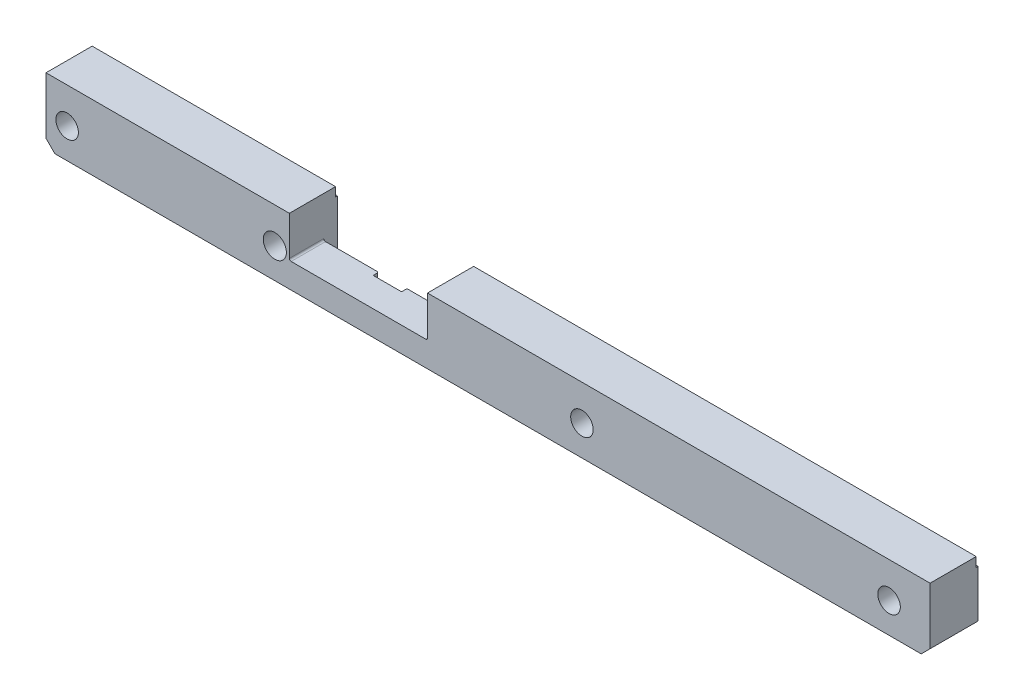
from build123d import *

# Parameters (mm, degrees)
SKETCH1_W               = 498
SKETCH1_H               = 37
BOSS_EXTRUDE1_DEPTH     = 27
SKETCH3_W               = 30
SKETCH3_H               = 27
CUT_EXTRUDE2_DEPTH      = 4
SKETCH4_W               = 77.8
SKETCH4_H               = 23
CUT_EXTRUDE3_DEPTH      = 28
SKETCH5_W               = 77.8
SKETCH5_H               = 7.65
CUT_EXTRUDE4_DEPTH      = 15
SKETCH6_W               = 16
SKETCH6_H               = 14
CUT_EXTRUDE5_DEPTH      = 3.05
CUT_EXTRUDE6_DEPTH      = 1
M3_TAPPED_HOLE1_D       = 2.5
M3_TAPPED_HOLE1_DEPTH   = 6
M3_TAPPED_HOLE1_TIP     = 0.751075774
M4_TAPPED_HOLE1_D       = 3.3
M4_TAPPED_HOLE1_DEPTH   = 8
M4_TAPPED_HOLE1_TIP     = 0.991420021
M3_TAPPED_HOLE2_D       = 2.5
M3_TAPPED_HOLE2_DEPTH   = 6
M3_TAPPED_HOLE2_TIP     = 0.751075774
M3_TAPPED_HOLE3_D       = 2.5
M3_TAPPED_HOLE3_DEPTH   = 6
M3_TAPPED_HOLE3_TIP     = 0.751075774
SKETCH16_W              = 10
SKETCH16_H              = 33
CUT_EXTRUDE7_DEPTH      = 0.4
FILLET1_R               = 1
CHAMFER1_SIZE           = 0.5
FILLET2_R               = 1
CHAMFER2_SIZE           = 5
SKETCH17_R              = 1.5
CUT_EXTRUDE8_DEPTH      = 6
SKETCH19_R              = 6.347203473
SKETCH19_R_2            = 6.528534634
CUT_EXTRUDE9_DEPTH      = 28
M3_5_TAPPED_HOLE1_D     = 2.9
M3_5_TAPPED_HOLE1_DEPTH = 5
M3_5_TAPPED_HOLE1_TIP   = 0.871247898
M4_TAPPED_HOLE3_D       = 3.3
M4_TAPPED_HOLE3_DEPTH   = 7
M4_TAPPED_HOLE3_TIP     = 0.991420021


with BuildPart() as part:
    # Sketch1 → Boss-Extrude1 (new body)
    with BuildSketch(Plane.XY):
        with Locations((97.902272727, 23.094318182)):
            Rectangle(SKETCH1_W, SKETCH1_H)
    extrude(amount=BOSS_EXTRUDE1_DEPTH)

    # Sketch3 → Cut-Extrude2 (cut)
    with BuildSketch(Plane(origin=(0, 0, 0), x_dir=(-1, 0, 0), z_dir=(0, 0, -1))):
        with Locations((-279.902272727, 18.094318182)):
            Rectangle(SKETCH3_W, SKETCH3_H)
    extrude(amount=-CUT_EXTRUDE2_DEPTH, mode=Mode.SUBTRACT)

    # Sketch4 → Cut-Extrude3 (cut, through all)
    with BuildSketch(Plane(origin=(0, 0, 0), x_dir=(-1, 0, 0), z_dir=(0, 0, -1))):
        with Locations((-24.902272727, 30.094318182)):
            Rectangle(SKETCH4_W, SKETCH4_H)
    extrude(amount=-CUT_EXTRUDE3_DEPTH, mode=Mode.SUBTRACT)

    # Sketch5 → Cut-Extrude4 (cut, through all)
    with BuildSketch(Plane(origin=(0, 18.594318182, 0), x_dir=(1, 0, 0), z_dir=(0, 1, 0))):
        with Locations((24.902272727, -3.825)):
            Rectangle(SKETCH5_W, SKETCH5_H)
    extrude(amount=-CUT_EXTRUDE4_DEPTH, mode=Mode.SUBTRACT)

    # Sketch6 → Cut-Extrude5 (cut)
    with BuildSketch(Plane(origin=(0, 0, 7.65), x_dir=(-1, 0, 0), z_dir=(0, 0, -1))):
        with Locations((-24.902272727, 11.594318182)):
            Rectangle(SKETCH6_W, SKETCH6_H)
    extrude(amount=-CUT_EXTRUDE5_DEPTH, mode=Mode.SUBTRACT)

    # Sketch7 → Cut-Extrude6 (cut)
    with BuildSketch(Plane(origin=(0, 0, 0), x_dir=(-1, 0, 0), z_dir=(0, 0, -1))):
        Polygon((151.097727273, 36.25457222), (146.097727273, 37.594318182), (18.242292409, 37.594318182), (13.997727273, 36.456990381), (13.997727273, 37.594318182), (-63.802272727, 37.594318182), (-341.902272727, 37.594318182), (-346.902272727, 36.25457222), (-346.902272727, 41.594318182), (151.097727273, 41.594318182), align=None)
    extrude(amount=-CUT_EXTRUDE6_DEPTH, mode=Mode.SUBTRACT)

    # M3 Tapped Hole1
    with Locations(Plane(origin=(0, 4.594318182, 0), x_dir=(-1, 0, 0), z_dir=(0, -1, 0))):
        with Locations((-286.402272727, -11.76), (-273.402272727, -11.76)):
            Hole(M3_TAPPED_HOLE1_D / 2, depth=M3_TAPPED_HOLE1_DEPTH)
            with Locations((0, 0, -(M3_TAPPED_HOLE1_DEPTH + M3_TAPPED_HOLE1_TIP / 2))):  # 118° drill point
                Cone(0, M3_TAPPED_HOLE1_D / 2, M3_TAPPED_HOLE1_TIP, mode=Mode.SUBTRACT)

    # M4 Tapped Hole1
    with Locations(Plane(origin=(0, 0, 7.65), x_dir=(-1, 0, 0), z_dir=(0, 0, -1))):
        with Locations((5.097727273, 11.594318182), (-54.902272727, 11.594318182)):
            Hole(M4_TAPPED_HOLE1_D / 2, depth=M4_TAPPED_HOLE1_DEPTH)
            with Locations((0, 0, -(M4_TAPPED_HOLE1_DEPTH + M4_TAPPED_HOLE1_TIP / 2))):  # 118° drill point
                Cone(0, M4_TAPPED_HOLE1_D / 2, M4_TAPPED_HOLE1_TIP, mode=Mode.SUBTRACT)

    # M3 Tapped Hole2
    with Locations(Plane(origin=(0, 0, 0), x_dir=(-1, 0, 0), z_dir=(0, 0, -1))):
        with Locations((71.097727273, 31.594318182), (41.097727273, 31.594318182), (-99.902272727, 31.594318182), (-151.902272727, 31.594318182), (-206.902272727, 31.594318182), (-221.902272727, 31.594318182), (-354.592417471, -112.457729383)):
            Hole(M3_TAPPED_HOLE2_D / 2, depth=M3_TAPPED_HOLE2_DEPTH)
            with Locations((0, 0, -(M3_TAPPED_HOLE2_DEPTH + M3_TAPPED_HOLE2_TIP / 2))):  # 118° drill point
                Cone(0, M3_TAPPED_HOLE2_D / 2, M3_TAPPED_HOLE2_TIP, mode=Mode.SUBTRACT)

    # M3 Tapped Hole3
    with Locations(Plane(origin=(0, 4.594318182, 0), x_dir=(-1, 0, 0), z_dir=(0, -1, 0))):
        with Locations((12.397727273, -14.1), (4.397727273, -14.1)):
            Hole(M3_TAPPED_HOLE3_D / 2, depth=M3_TAPPED_HOLE3_DEPTH)
            with Locations((0, 0, -(M3_TAPPED_HOLE3_DEPTH + M3_TAPPED_HOLE3_TIP / 2))):  # 118° drill point
                Cone(0, M3_TAPPED_HOLE3_D / 2, M3_TAPPED_HOLE3_TIP, mode=Mode.SUBTRACT)

    # Sketch16 → Cut-Extrude7 (cut)
    with BuildSketch(Plane(origin=(0, 0, 0), x_dir=(-1, 0, 0), z_dir=(0, 0, -1))):
        with Locations((-84.402272727, 21.094318182)):
            Rectangle(SKETCH16_W, SKETCH16_H)
    extrude(amount=-CUT_EXTRUDE7_DEPTH, mode=Mode.SUBTRACT)

    # Fillet1
    fillet1_edges = [part.edges().sort_by_distance(p)[0] for p in [
        (-13.997727273, 18.594318182, 17.325),
        (63.802272727, 18.594318182, 17.325),
    ]]
    fillet(fillet1_edges, radius=FILLET1_R)

    # Chamfer1
    chamfer1_edges = [part.edges().sort_by_distance(p)[0] for p in [
        (16.902272727, 11.594318182, 7.65),
        (32.902272727, 11.594318182, 7.65),
    ]]
    chamfer(chamfer1_edges, length=CHAMFER1_SIZE)

    # Fillet2
    fillet2_edges = [part.edges().sort_by_distance(p)[0] for p in [
        (264.902272727, 31.594318182, 2),
        (294.902272727, 31.594318182, 2),
    ]]
    fillet(fillet2_edges, radius=FILLET2_R)

    # Chamfer2
    chamfer2_edges = [part.edges().sort_by_distance(p)[0] for p in [
        (346.902272727, 4.594318182, 13.5),
        (-151.097727273, 4.594318182, 13.5),
    ]]
    chamfer(chamfer2_edges, length=CHAMFER2_SIZE)

    # Sketch17 → Cut-Extrude8 (cut)
    with BuildSketch(Plane(origin=(0, 0, 0), x_dir=(-1, 0, 0), z_dir=(0, 0, -1))):
        with Locations((-323.902272727, 27.594318182)):
            Circle(SKETCH17_R)
        with Locations((-337.902272727, 27.594318182)):
            Circle(SKETCH17_R)
    extrude(amount=-CUT_EXTRUDE8_DEPTH, mode=Mode.SUBTRACT)

    # Sketch19 → Cut-Extrude9 (cut, through all)
    with BuildSketch(Plane.XY.offset(27)):
        with Locations((-139.197727273, 21.594318182)):
            Circle(SKETCH19_R)
        with Locations((-22.197727273, 21.594318182)):
            Circle(SKETCH19_R_2)
        with Locations((150.802272727, 21.594318182)):
            Circle(SKETCH19_R)
        with Locations((323.802272727, 21.594318182)):
            Circle(SKETCH19_R)
    extrude(amount=-CUT_EXTRUDE9_DEPTH, mode=Mode.SUBTRACT)

    # M3.5 Tapped Hole1
    with Locations(Plane(origin=(0, 4.594318182, 0), x_dir=(-1, 0, 0), z_dir=(0, -1, 0))):
        with Locations((-131.42052192, -2.174485534), (-131.42052192, -14.174485534), (-81.42052192, -2.174485534)):
            Hole(M3_5_TAPPED_HOLE1_D / 2, depth=M3_5_TAPPED_HOLE1_DEPTH)
            with Locations((0, 0, -(M3_5_TAPPED_HOLE1_DEPTH + M3_5_TAPPED_HOLE1_TIP / 2))):  # 118° drill point
                Cone(0, M3_5_TAPPED_HOLE1_D / 2, M3_5_TAPPED_HOLE1_TIP, mode=Mode.SUBTRACT)

    # M4 Tapped Hole3
    with Locations(Plane(origin=(0, 0, 0), x_dir=(-1, 0, 0), z_dir=(0, 0, -1))):
        with Locations((-246.689139378, 8.594318182), (-246.689139378, 20.594318182)):
            Hole(M4_TAPPED_HOLE3_D / 2, depth=M4_TAPPED_HOLE3_DEPTH)
            with Locations((0, 0, -(M4_TAPPED_HOLE3_DEPTH + M4_TAPPED_HOLE3_TIP / 2))):  # 118° drill point
                Cone(0, M4_TAPPED_HOLE3_D / 2, M4_TAPPED_HOLE3_TIP, mode=Mode.SUBTRACT)


solid = part.part
